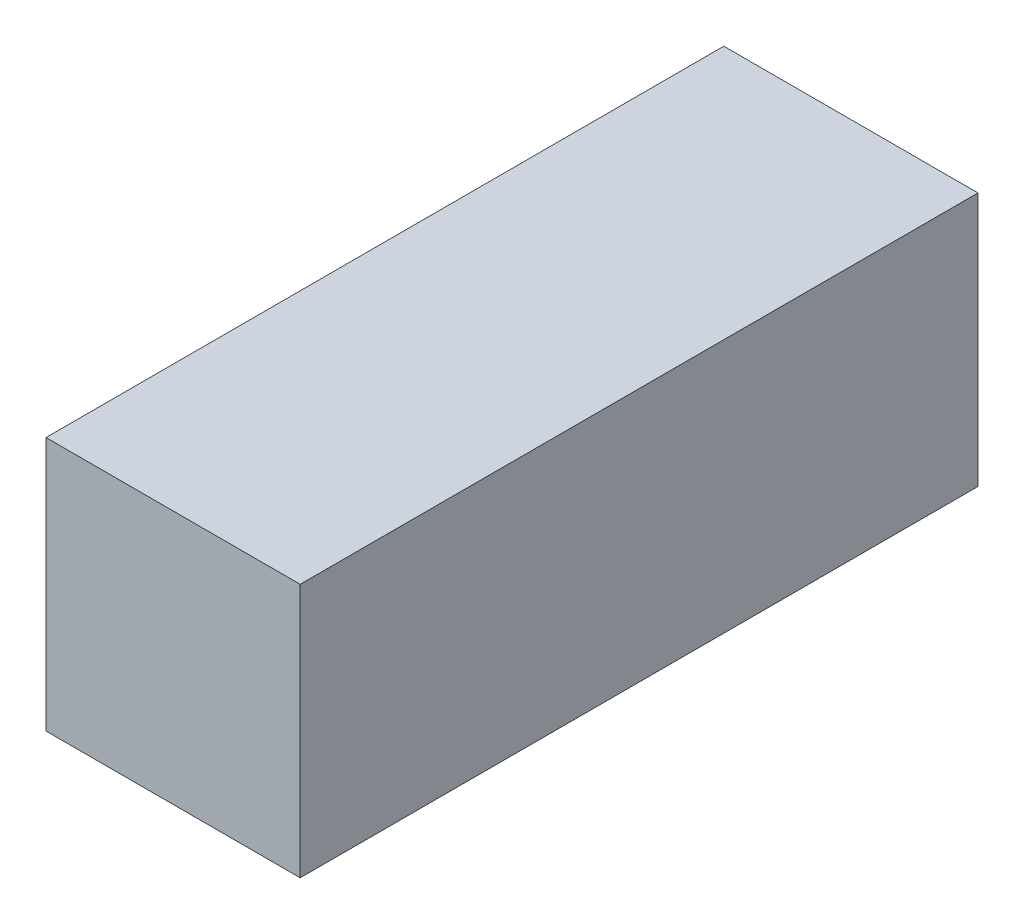
from build123d import *

# Parameters (mm, degrees)
SKETCH1_W           = 15
SKETCH1_H           = 15
BOSS_EXTRUDE1_DEPTH = 20
SKETCH2_R           = 5
CUT_EXTRUDE1_DEPTH  = 17.5


with BuildPart() as part:
    # Sketch1 → Boss-Extrude1 (new body, symmetric)
    with BuildSketch(Plane.XY):
        Rectangle(SKETCH1_W, SKETCH1_H)
    extrude(amount=BOSS_EXTRUDE1_DEPTH, both=True)

    # Sketch2 → Cut-Extrude1 (cut, symmetric)
    with BuildSketch(Plane.XY):
        Circle(SKETCH2_R)
    extrude(amount=CUT_EXTRUDE1_DEPTH, both=True, mode=Mode.SUBTRACT)


solid = part.part
